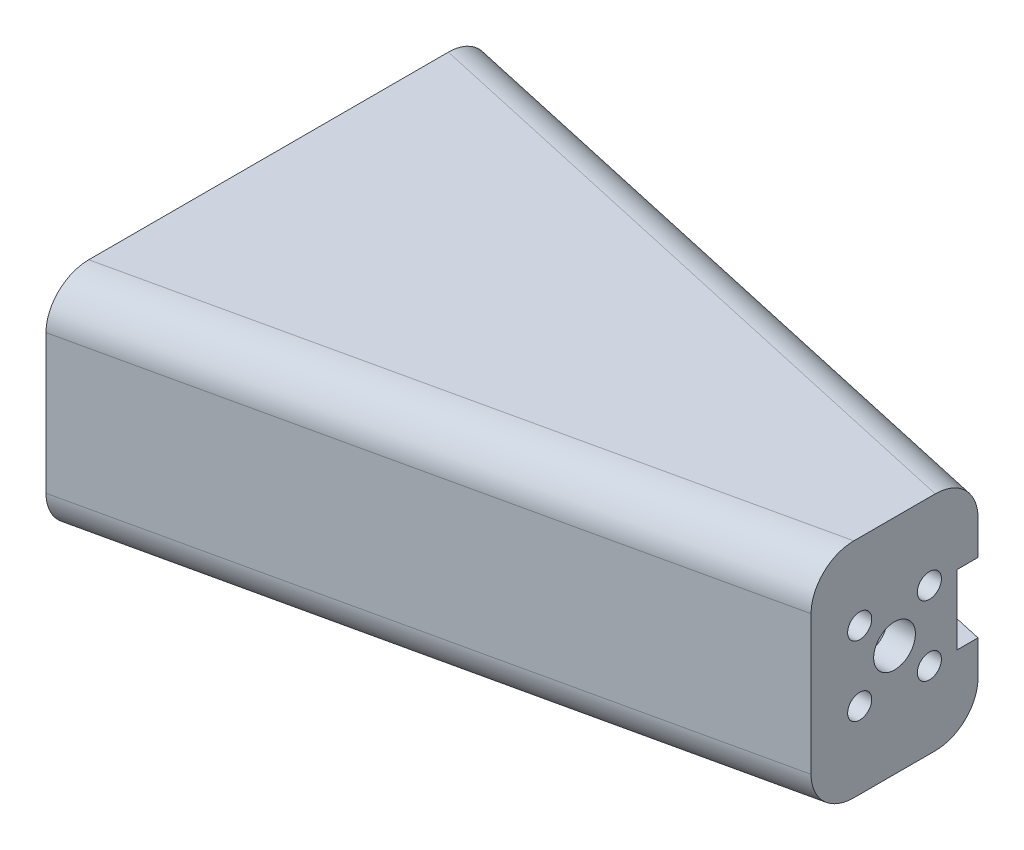
from build123d import *

# Parameters (mm, degrees)
BOSS_EXTRUDE1_DEPTH = 17.78
SKETCH4_R           = 1.905
SKETCH4_R_2         = 1.1
SKETCH4_W           = 3.81
SKETCH4_H           = 6.35
CUT_EXTRUDE1_DEPTH  = 7.62
BOSS_EXTRUDE2_DEPTH = 1.27
BOSS_EXTRUDE3_DEPTH = 1.27
FILLET1_R           = 3.81


with BuildPart() as part:
    # Sketch3 → Boss-Extrude1 (new body)
    with BuildSketch(Plane(origin=(0, 0, 0), x_dir=(1, 0, 0), z_dir=(0, 1, 0))):
        Polygon((0, 20.32), (57.15, 7.62), (57.15, -7.62), (0, -20.32), (0, -17.718039675), (54.61, -5.58248412), (54.61, 5.58248412), (0, 17.718039675), align=None)
    extrude(amount=BOSS_EXTRUDE1_DEPTH)

    # Sketch4 → Cut-Extrude1 (cut)
    with BuildSketch(Plane(origin=(57.15, 0, 0), x_dir=(0, 0, -1), z_dir=(1, 0, 0))):
        with Locations((0, 8.89)):
            Circle(SKETCH4_R)
        with Locations((-3.181980515, 12.071980515)):
            Circle(SKETCH4_R_2)
        with Locations((3.181980515, 12.071980515)):
            Circle(SKETCH4_R_2)
        with Locations((3.181980515, 5.708019485)):
            Circle(SKETCH4_R_2)
        with Locations((-3.181980515, 5.708019485)):
            Circle(SKETCH4_R_2)
        with Locations((7.62, 8.89)):
            Rectangle(SKETCH4_W, SKETCH4_H)
    extrude(amount=-CUT_EXTRUDE1_DEPTH, mode=Mode.SUBTRACT)

    # Sketch5 → Boss-Extrude2 (add)
    with BuildSketch(Plane(origin=(0, 17.78, 0), x_dir=(1, 0, 0), z_dir=(0, 1, 0))):
        Polygon((0, 20.32), (0, -20.32), (57.15, -7.62), (57.15, 7.62), align=None)
    extrude(amount=BOSS_EXTRUDE2_DEPTH)

    # Sketch6 → Boss-Extrude3 (add)
    with BuildSketch(Plane.XZ):
        Polygon((0, 20.32), (0, -20.32), (57.15, -7.62), (57.15, 7.62), align=None)
    extrude(amount=BOSS_EXTRUDE3_DEPTH)

    # Fillet1
    fillet1_edges = [part.edges().sort_by_distance(p)[0] for p in [
        (28.575, 19.05, -13.97),
        (28.575, 19.05, 13.97),
        (28.575, -1.27, 13.97),
        (28.575, -1.27, -13.97),
    ]]
    fillet(fillet1_edges, radius=FILLET1_R)


solid = part.part
